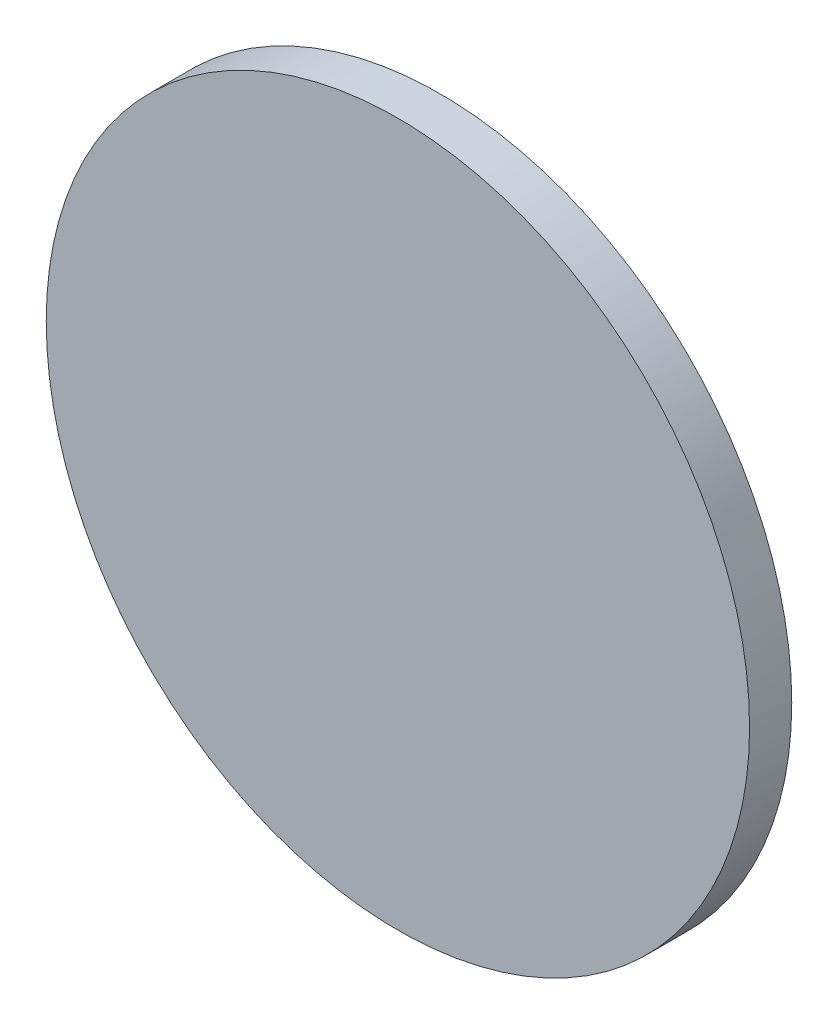
from build123d import *

# Parameters (mm, degrees)
SKETCH1_R           = 44.45
BOSS_EXTRUDE1_DEPTH = 2.667


with BuildPart() as part:
    # Sketch1 → Boss-Extrude1 (new body, symmetric)
    with BuildSketch(Plane.XY):
        Circle(SKETCH1_R)
    extrude(amount=BOSS_EXTRUDE1_DEPTH, both=True)


solid = part.part
